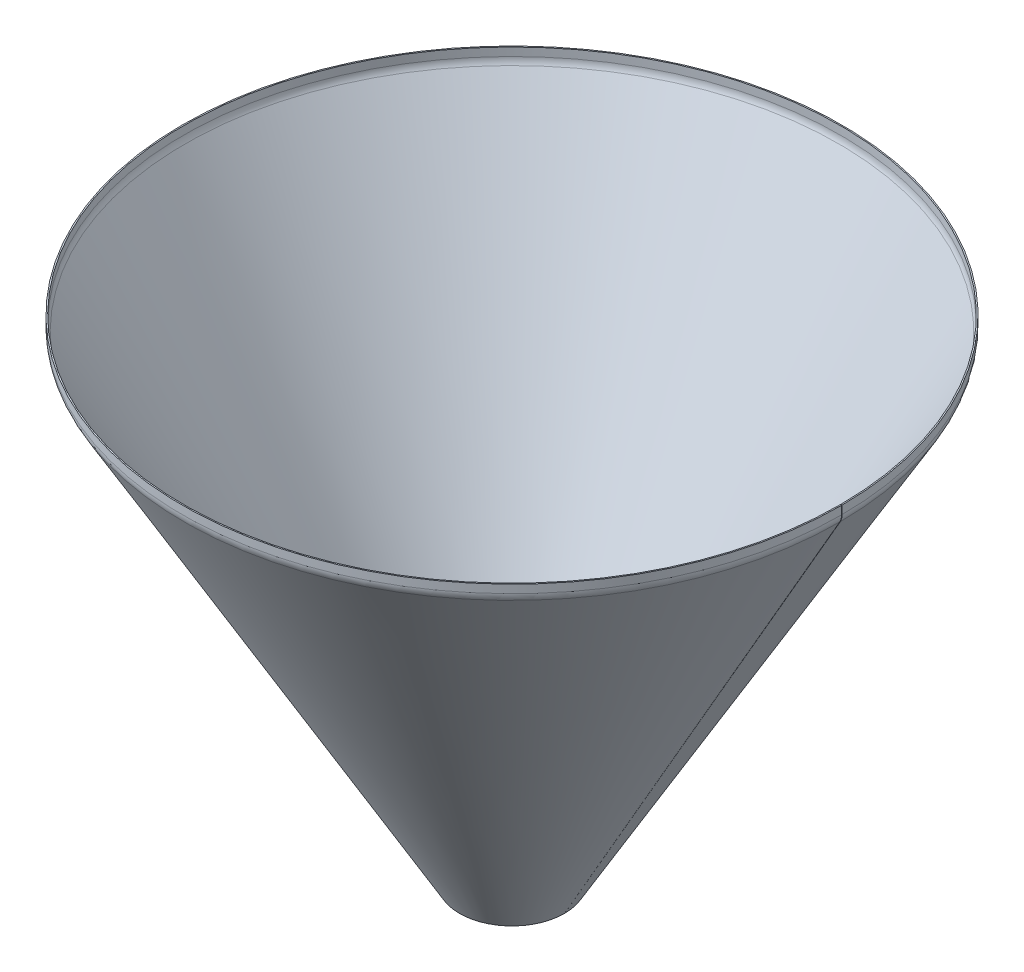
from build123d import *

# Parameters (mm, degrees)
ROTATION_D_NN4_ANGLE = 359.9


with BuildPart() as part:
    # Skizze1 → Rotation-Dünn4 (revolve)
    with BuildSketch(Plane.XY):
        with BuildLine():
            Line((0, 0), (0, -20))
            ThreePointArc((0, -20), (-1.19259608, -29.058666579), (-4.689110868, -37.5))
            Line((-4.689110868, -37.5), (-672.5, -1194.182389825))
            Line((-672.5, -1194.182389825), (-675.098076211, -1192.682389825))
            Line((-675.098076211, -1192.682389825), (-7.287187079, -36))
            ThreePointArc((-7.287187079, -36), (-4.090373559, -28.282209443), (-3, -20))
            Line((-3, -20), (-3, 0))
            Line((-3, 0), (0, 0))
        make_face()
    revolve(axis=Axis((-800, 0, 0), (0, -1, 0)), revolution_arc=ROTATION_D_NN4_ANGLE)


solid = part.part
